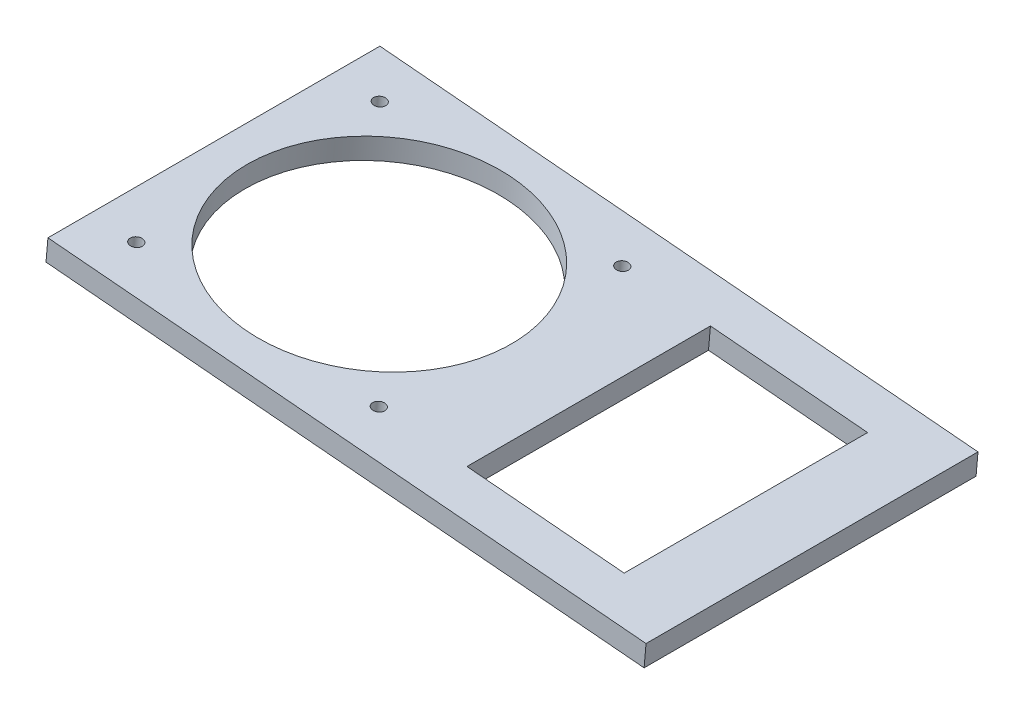
from build123d import *

# Parameters (mm, degrees)
BOSS_EXTRUDE1_DEPTH = 95.25
SKETCH3_R           = 38.1
CUT_EXTRUDE1_DEPTH  = 22.306729365
SKETCH4_R           = 1.75
CUT_EXTRUDE2_DEPTH  = 22.306729365
SKETCH5_W           = 45.264743179
SKETCH5_H           = 69.85
CUT_EXTRUDE3_DEPTH  = 22.306729365


with BuildPart() as part:
    # Sketch2 → Boss-Extrude1 (new body)
    with BuildSketch(Plane.XY):
        Polygon((-137.563755829, 331.29726238), (-138.117194795, 324.971426047), (33.492029028, 309.957564406), (34.045467994, 316.283400739), align=None)
    extrude(amount=BOSS_EXTRUDE1_DEPTH)

    # Sketch3 → Cut-Extrude1 (cut, through all)
    with BuildSketch(Plane(origin=(27.719631662, 316.836839705, 0), x_dir=(0.996194698, -0.087155743, 0), z_dir=(0.087155743, 0.996194698, 0))):
        with Locations((-118.289743179, -47.625)):
            Circle(SKETCH3_R)
    extrude(amount=-CUT_EXTRUDE1_DEPTH, mode=Mode.SUBTRACT)

    # Sketch4 → Cut-Extrude2 (cut, through all)
    with BuildSketch(Plane(origin=(27.719631662, 316.836839705, 0), x_dir=(0.996194698, -0.087155743, 0), z_dir=(0.087155743, 0.996194698, 0))):
        with Locations((-153.214743179, -12.7)):
            Circle(SKETCH4_R)
        with Locations((-153.214743179, -82.55)):
            Circle(SKETCH4_R)
        with Locations((-83.364743179, -82.55)):
            Circle(SKETCH4_R)
        with Locations((-83.364743179, -12.7)):
            Circle(SKETCH4_R)
    extrude(amount=-CUT_EXTRUDE2_DEPTH, mode=Mode.SUBTRACT)

    # Sketch5 → Cut-Extrude3 (cut, through all)
    with BuildSketch(Plane(origin=(27.719631662, 316.836839705, 0), x_dir=(0.996194698, -0.087155743, 0), z_dir=(0.087155743, 0.996194698, 0))):
        with Locations((-35.332371589, -47.625)):
            Rectangle(SKETCH5_W, SKETCH5_H)
    extrude(amount=-CUT_EXTRUDE3_DEPTH, mode=Mode.SUBTRACT)


solid = part.part
